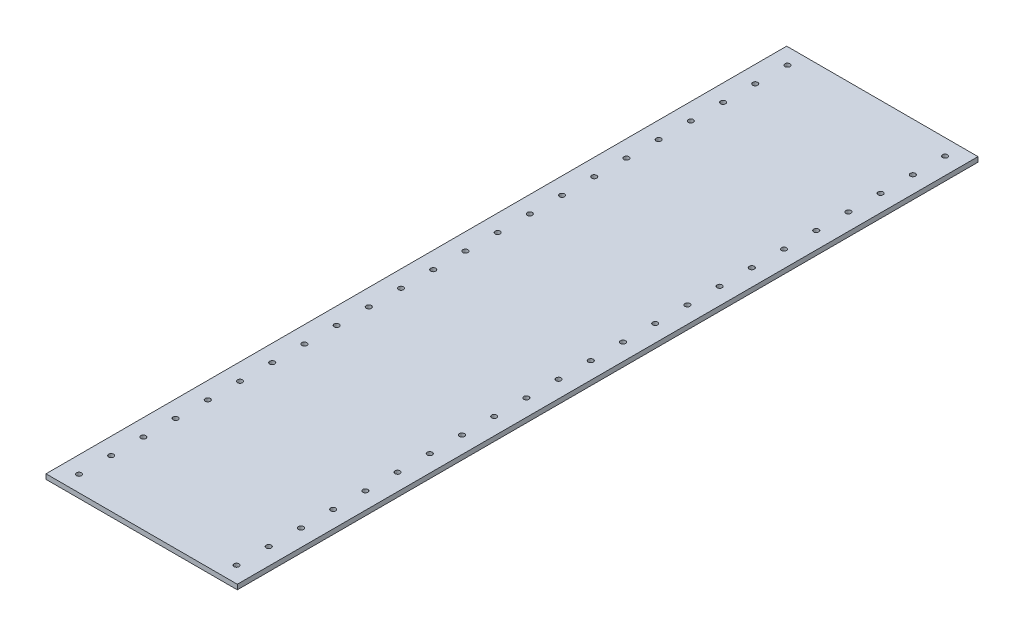
from build123d import *

# Parameters (mm, degrees)
SKETCH1_W                   = 124.76
SKETCH1_H                   = 483
BOSS_EXTRUDE1_DEPTH         = 3.175
TAP_DRILL_FOR_M4X0_7_TAP1_D = 3.3


with BuildPart() as part:
    # Sketch1 → Boss-Extrude1 (new body)
    with BuildSketch(Plane(origin=(0, 0, 0), x_dir=(1, 0, 0), z_dir=(0, 1, 0))):
        Rectangle(SKETCH1_W, SKETCH1_H)
    extrude(amount=BOSS_EXTRUDE1_DEPTH)

    # Tap Drill for M4x0.7 Tap1 (through all)
    with Locations(Plane(origin=(0, 3.175, 0), x_dir=(1, 0, 0), z_dir=(0, 1, 0))):
        with Locations((-51.38, -231), (-51.38, -210), (-51.38, -189), (-51.38, -168), (-51.38, -147), (-51.38, -126), (-51.38, -105), (-51.38, -84), (-51.38, -63), (-51.38, -42), (-51.38, -21), (-51.38, 0), (-51.38, 21), (-51.38, 42), (-51.38, 63), (-51.38, 84), (-51.38, 105), (-51.38, 126), (-51.38, 147), (-51.38, 168), (-51.38, 189), (-51.38, 210), (-51.38, 231), (51.38, -210), (51.38, -189), (51.38, -168), (51.38, -147), (51.38, -126), (51.38, -105), (51.38, -84), (51.38, -63), (51.38, -42), (51.38, -21), (51.38, 0), (51.38, 21), (51.38, 42), (51.38, 63), (51.38, 84), (51.38, 105), (51.38, 126), (51.38, 147), (51.38, 168), (51.38, 189), (51.38, 210), (51.38, 231), (51.38, -231)):
            Hole(TAP_DRILL_FOR_M4X0_7_TAP1_D / 2)


solid = part.part
